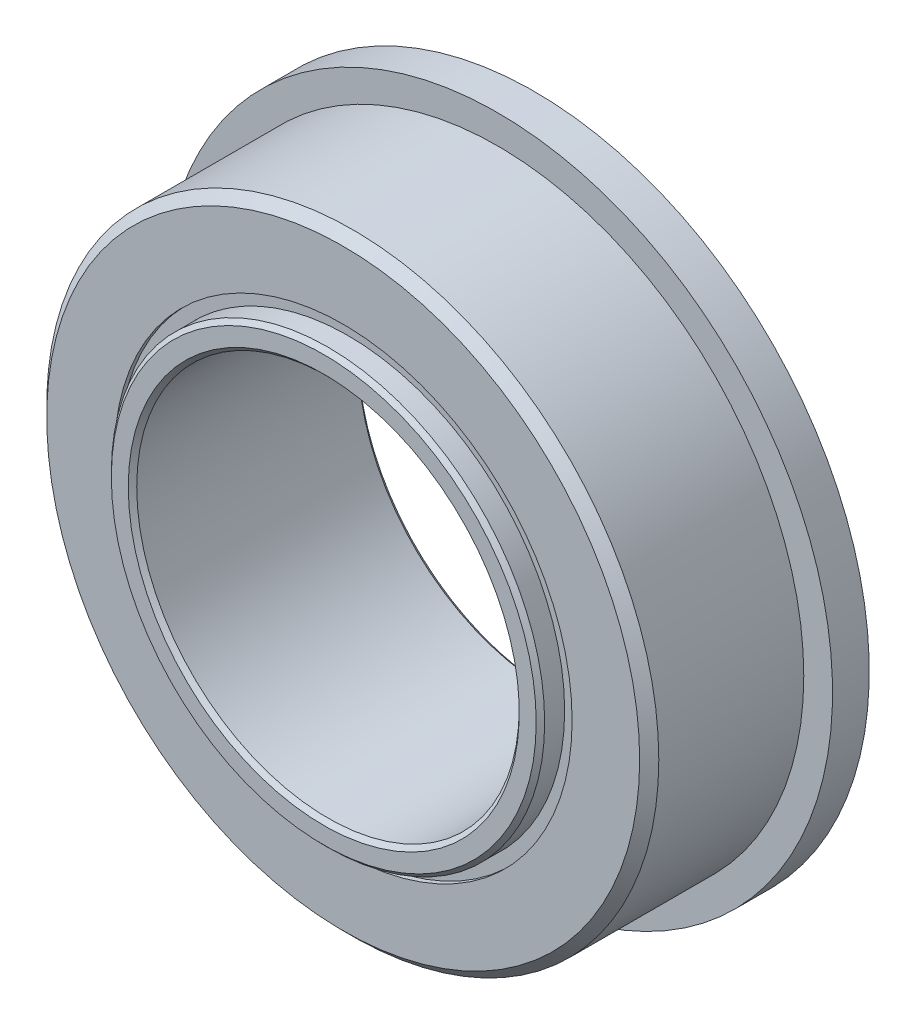
from build123d import *

# Parameters (mm, degrees)
CHAMFER1_SIZE     = 0.087841667
CIRPATTERN1_COUNT = 12
SKETCH5_W         = 1.223697917
SKETCH5_H         = 0.254
SKETCH6_W         = 0.762
SKETCH6_H         = 2.1971


with BuildPart() as part:
    # Sketch1 → Revolve1 (revolve)
    with BuildSketch(Plane(origin=(0, 0, 0), x_dir=(0, 0, -1), z_dir=(1, 0, 0))):
        with BuildLine():
            Line((1.7859375, 6.35), (-1.7859375, 6.35))
            Line((-1.7859375, 6.35), (-1.984375, 6.1515625))
            Line((-1.984375, 6.1515625), (-1.984375, 4.7498))
            Line((-1.984375, 4.7498), (-0.64560849, 4.7498))
            ThreePointArc((-0.64560849, 4.7498), (0, 5.555191667), (0.64560849, 4.7498))
            Line((0.64560849, 4.7498), (1.984375, 4.7498))
            Line((1.984375, 4.7498), (1.984375, 6.1515625))
            Line((1.984375, 6.1515625), (1.7859375, 6.35))
        make_face()
        with BuildLine():
            Line((2.3876, 4.4958), (0.528371261, 4.4958))
            ThreePointArc((0.528371261, 4.4958), (0, 4.232275), (-0.528371261, 4.4958))
            Line((-0.528371261, 4.4958), (-2.3876, 4.4958))
            Line((-2.3876, 4.4958), (-2.3876, 3.96875))
            Line((-2.3876, 3.96875), (2.3876, 3.96875))
            Line((2.3876, 3.96875), (2.3876, 4.4958))
        make_face()
    revolve(axis=Axis((0, 0, 1.984375), (0, 0, -1)))

    # Chamfer1
    chamfer1_edges = [part.edges().sort_by_distance(p)[0] for p in [
        (0, -4.4958, -2.3876),
        (0, -3.96875, -2.3876),
        (0, -3.96875, 2.3876),
        (0, -4.4958, 2.3876),
    ]]
    chamfer(chamfer1_edges, length=CHAMFER1_SIZE)

    # Sketch6 → Revolve6 (revolve)
    with BuildSketch(Plane(origin=(0, 0, 0), x_dir=(0, 0, -1), z_dir=(1, 0, 0))):
        with Locations((1.603375, 5.84835)):
            Rectangle(SKETCH6_W, SKETCH6_H)
    revolve(axis=Axis((0, 0, -1.984375), (0, 0, 1)))


with BuildPart() as body_2:
    # Sketch4 → Revolve4 (revolve)
    with BuildSketch(Plane(origin=(0, 0, 0), x_dir=(0, 0, -1), z_dir=(1, 0, 0))):
        with BuildLine():
            Line((-0.661458333, 4.893733333), (0.661458333, 4.893733333))
            ThreePointArc((0.661458333, 4.893733333), (0, 5.555191667), (-0.661458333, 4.893733333))
        make_face()
    revolve(axis=Axis((0, 4.893733333, 0.661458333), (0, 0, -1)))


with BuildPart() as cirpattern1_1:
    # CirPattern1: pattern copy
    add(body_2.part.rotate(Axis((0, 0, 0), (0, 0, 1)), 1 * 360 / CIRPATTERN1_COUNT))


with BuildPart() as cirpattern1_2:
    # CirPattern1: pattern copy
    add(body_2.part.rotate(Axis((0, 0, 0), (0, 0, 1)), 2 * 360 / CIRPATTERN1_COUNT))


with BuildPart() as cirpattern1_3:
    # CirPattern1: pattern copy
    add(body_2.part.rotate(Axis((0, 0, 0), (0, 0, 1)), 3 * 360 / CIRPATTERN1_COUNT))


with BuildPart() as cirpattern1_4:
    # CirPattern1: pattern copy
    add(body_2.part.rotate(Axis((0, 0, 0), (0, 0, 1)), 4 * 360 / CIRPATTERN1_COUNT))


with BuildPart() as cirpattern1_5:
    # CirPattern1: pattern copy
    add(body_2.part.rotate(Axis((0, 0, 0), (0, 0, 1)), 5 * 360 / CIRPATTERN1_COUNT))


with BuildPart() as cirpattern1_6:
    # CirPattern1: pattern copy
    add(body_2.part.rotate(Axis((0, 0, 0), (0, 0, 1)), 6 * 360 / CIRPATTERN1_COUNT))


with BuildPart() as cirpattern1_7:
    # CirPattern1: pattern copy
    add(body_2.part.rotate(Axis((0, 0, 0), (0, 0, 1)), 7 * 360 / CIRPATTERN1_COUNT))


with BuildPart() as cirpattern1_8:
    # CirPattern1: pattern copy
    add(body_2.part.rotate(Axis((0, 0, 0), (0, 0, 1)), 8 * 360 / CIRPATTERN1_COUNT))


with BuildPart() as cirpattern1_9:
    # CirPattern1: pattern copy
    add(body_2.part.rotate(Axis((0, 0, 0), (0, 0, 1)), 9 * 360 / CIRPATTERN1_COUNT))


with BuildPart() as cirpattern1_10:
    # CirPattern1: pattern copy
    add(body_2.part.rotate(Axis((0, 0, 0), (0, 0, 1)), 10 * 360 / CIRPATTERN1_COUNT))


with BuildPart() as cirpattern1_11:
    # CirPattern1: pattern copy
    add(body_2.part.rotate(Axis((0, 0, 0), (0, 0, 1)), 11 * 360 / CIRPATTERN1_COUNT))


with BuildPart() as body_14:
    # Sketch5 → Revolve5 (revolve)
    with BuildSketch(Plane(origin=(0, 0, 0), x_dir=(0, 0, -1), z_dir=(1, 0, 0))):
        with Locations((-1.273307292, 4.6228)):
            Rectangle(SKETCH5_W, SKETCH5_H)
        with Locations((1.273307292, 4.6228)):
            Rectangle(SKETCH5_W, SKETCH5_H)
    revolve(axis=Axis((0, 0, 1.984375), (0, 0, -1)))


solid = Compound([part.part, body_2.part, cirpattern1_1.part, cirpattern1_2.part, cirpattern1_3.part, cirpattern1_4.part, cirpattern1_5.part, cirpattern1_6.part, cirpattern1_7.part, cirpattern1_8.part, cirpattern1_9.part, cirpattern1_10.part, cirpattern1_11.part, body_14.part])
